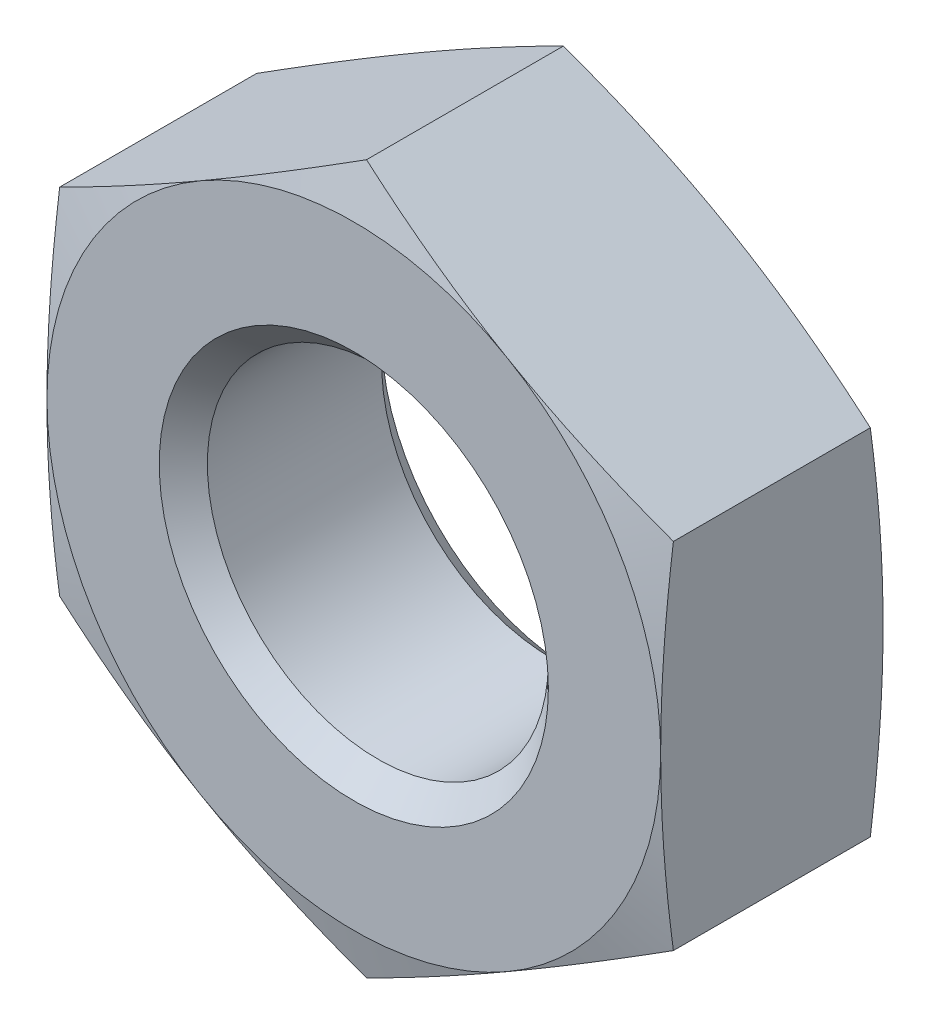
from build123d import *

# Parameters (mm, degrees)
SKETCH2_W          = 35.052
SKETCH2_H          = 35.052
CUT_EXTRUDE1_DEPTH = 6.35


with BuildPart() as part:
    # Sketch1 → Revolve1 (revolve)
    with BuildSketch(Plane(origin=(0, 0, 0), x_dir=(0, 0, -1), z_dir=(1, 0, 0))):
        Polygon((0, 0), (0, 8.763), (0.469607755, 10.5156), (5.880392245, 10.5156), (6.35, 8.763), (6.35, 0), align=None)
    revolve(axis=Axis((0, 0, -6.35), (0, 0, 1)))

    # Sketch2 → Cut-Extrude1 (cut)
    with BuildSketch(Plane.XY):
        Rectangle(SKETCH2_W, SKETCH2_H)
        Polygon((-8.763, -5.059320409), (0, -10.118640818), (8.763, -5.059320409), (8.763, 5.059320409), (0, 10.118640818), (-8.763, 5.059320409), align=None, mode=Mode.SUBTRACT)
    extrude(amount=-CUT_EXTRUDE1_DEPTH, mode=Mode.SUBTRACT)

    # Sketch3 → Cut-Revolve1 (revolve, cut)
    with BuildSketch(Plane(origin=(0, 0, 0), x_dir=(0, 0, -1), z_dir=(1, 0, 0))):
        Polygon((0, 0), (0, 5.55625), (0.68707, 4.86918), (5.66293, 4.86918), (6.35, 5.55625), (6.35, 0), align=None)
    revolve(axis=Axis((0, 0, -6.35), (0, 0, 1)), mode=Mode.SUBTRACT)


solid = part.part
